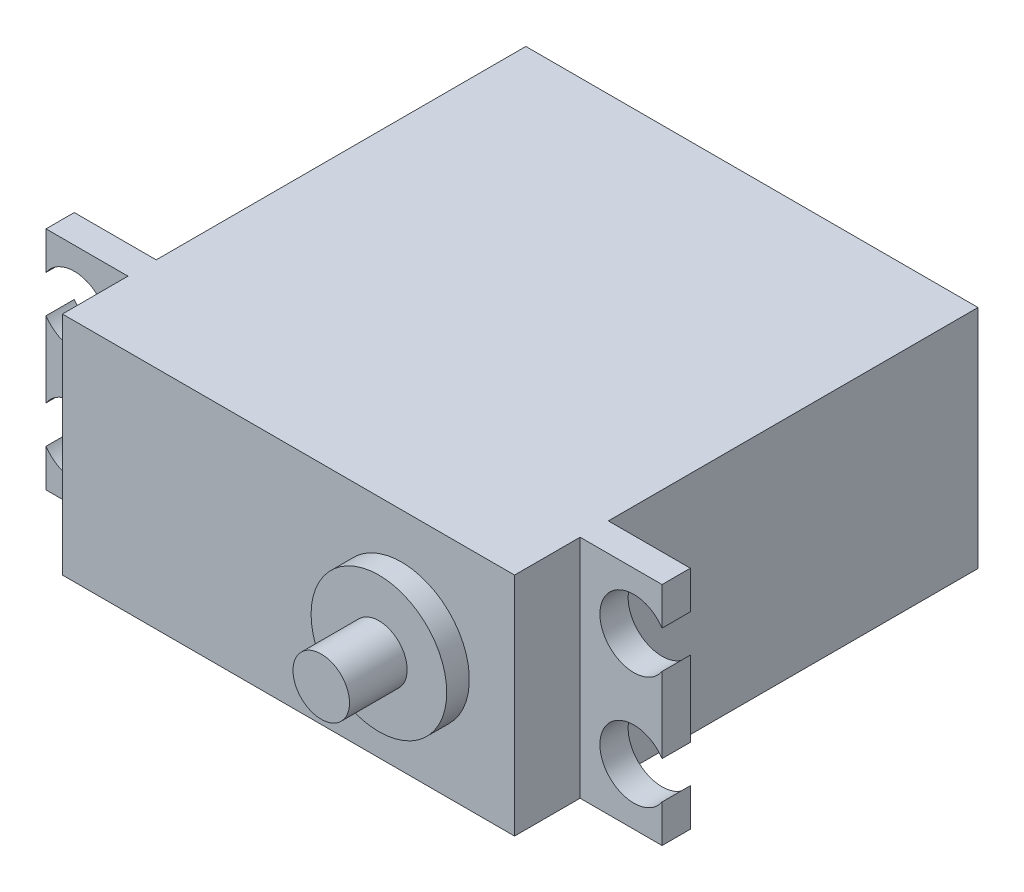
from build123d import *

# Parameters (mm, degrees)
SKETCH_1_W          = 40
SKETCH_1_H          = 41
EXTRUDE_1_DEPTH     = 20
SKETCH_2_R          = 6
EXTRUDE_2_DEPTH     = 2
SKETCH_3_R          = 2.5
EXTRUDE_3_DEPTH     = 5.1
SKETCH_4_W          = 2.5
SKETCH_4_H          = 20
EXTRUDE_4_DEPTH     = 7.25
SKETCH_5_R          = 3
CUT_EXTRUDE_2_DEPTH = 2.5


with BuildPart() as part:
    # 草图1 → 凸台-拉伸1 (new body)
    with BuildSketch(Plane(origin=(0, 0, 0), x_dir=(1, 0, 0), z_dir=(0, 1, 0))):
        with Locations((20, 20.5)):
            Rectangle(SKETCH_1_W, SKETCH_1_H)
    extrude(amount=EXTRUDE_1_DEPTH)

    # 草图2 → 凸台-拉伸2 (add)
    with BuildSketch(Plane.XY):
        with Locations((30, 10)):
            Circle(SKETCH_2_R)
    extrude(amount=EXTRUDE_2_DEPTH)

    # 草图3 → 凸台-拉伸3 (add)
    with BuildSketch(Plane.XY.offset(2)):
        with Locations((30, 10)):
            Circle(SKETCH_3_R)
    extrude(amount=EXTRUDE_3_DEPTH)

    # 草图4 → 凸台-拉伸4 (add)
    with BuildSketch(Plane.ZY):
        with Locations((-7.05, 10)):
            Rectangle(SKETCH_4_W, SKETCH_4_H)
    extrude_4 = extrude(amount=EXTRUDE_4_DEPTH)

    # 草图5 → 切除-拉伸2 (cut)
    with BuildSketch(Plane.XY.offset(-5.8)):
        with Locations((-4.75, 15)):
            Circle(SKETCH_5_R)
        with Locations((-4.75, 5)):
            Circle(SKETCH_5_R)
    cut_extrude_2 = extrude(amount=-CUT_EXTRUDE_2_DEPTH, mode=Mode.SUBTRACT)

    # 镜向1: 凸台-拉伸4, 切除-拉伸2 across plane
    add(extrude_4.mirror(Plane.ZY.offset(-20)))
    add(cut_extrude_2.mirror(Plane.ZY.offset(-20)), mode=Mode.SUBTRACT)


solid = part.part
